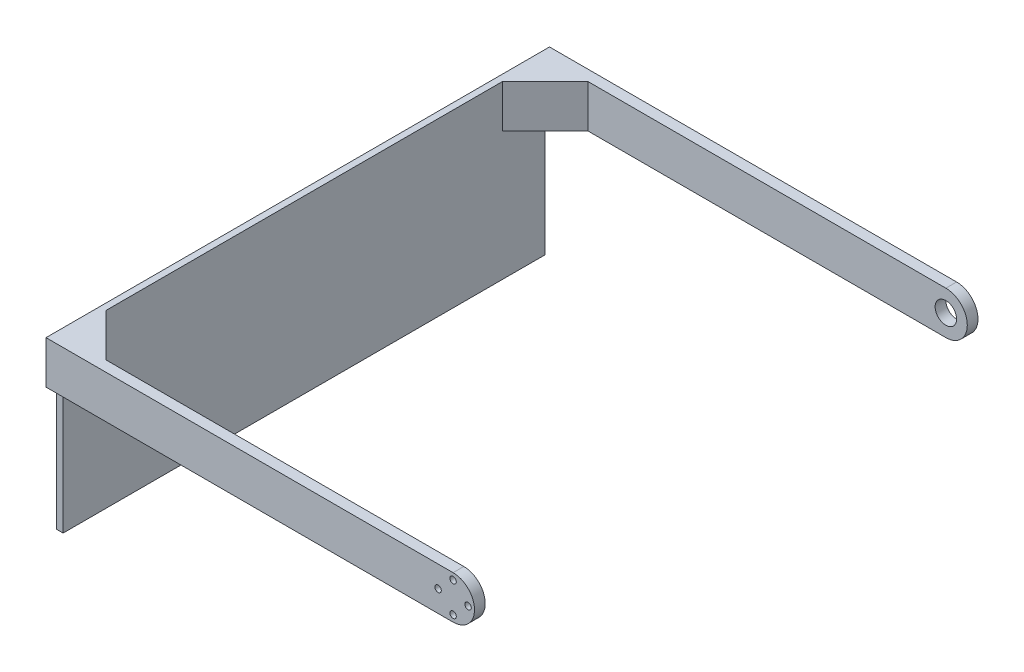
from build123d import *

# Parameters (mm, degrees)
SKETCH_1_R      = 1.5
EXTRUDE_1_DEPTH = 5
EXTRUDE_2_DEPTH = 225
RIB_1_REACH     = 307.164
SKETCH_3_WALL_W = 640.612052034
SKETCH_3_WALL_H = 20
SKETCH_4_R      = 5
EXTRUDE_3_DEPTH = 5


with BuildPart() as part:
    # 草图1 → 凸台-拉伸1 (new body)
    with BuildSketch(Plane.XY):
        with BuildLine():
            Line((0, 10), (-190, 10))
            Line((-190, 10), (-190, -10))
            Line((-190, -10), (0, -10))
            ThreePointArc((0, -10), (10, 0), (0, 10))
        make_face()
        with Locations((7, 0)):
            Circle(SKETCH_1_R, mode=Mode.SUBTRACT)
        with Locations((0, -7)):
            Circle(SKETCH_1_R, mode=Mode.SUBTRACT)
        with Locations((-7, 0)):
            Circle(SKETCH_1_R, mode=Mode.SUBTRACT)
        with Locations((0, 7)):
            Circle(SKETCH_1_R, mode=Mode.SUBTRACT)
    extrude(amount=EXTRUDE_1_DEPTH)

    # 草图2 → 凸台-拉伸2 (add)
    with BuildSketch(Plane(origin=(0, 0, 0), x_dir=(-1, 0, 0), z_dir=(0, 0, -1))):
        Polygon((190, 10), (190, -10), (190, -70), (187, -70), (187, -10), (187, 10), align=None)
    extrude(amount=EXTRUDE_2_DEPTH)

    # 草图3 wall → 筋1 (add, up to next)
    with BuildSketch(Plane(origin=(-177, 10, -10), x_dir=(0.707106781187, 0, 0.707106781187), z_dir=(0.707106781187, 0, -0.707106781187)), mode=Mode.PRIVATE) as rib_1_sk1:
        with Locations((0, 10)):
            Rectangle(SKETCH_3_WALL_W, SKETCH_3_WALL_H)
    rib_1_tool1 = extrude(rib_1_sk1.sketch, amount=-RIB_1_REACH, mode=Mode.PRIVATE) - part.part
    rib_1 = rib_1_tool1.solids().sort_by_distance((-177, 10, -10))[0]
    add(rib_1)

    # 草图4 → 凸台-拉伸3 (add)
    with BuildSketch(Plane(origin=(0, 0, -225), x_dir=(-1, 0, 0), z_dir=(0, 0, -1))):
        with BuildLine():
            Line((190, -10), (190, 10))
            Line((190, 10), (0, 10))
            ThreePointArc((0, 10), (-10, 0), (0, -10))
            Line((0, -10), (190, -10))
        make_face()
        Circle(SKETCH_4_R, mode=Mode.SUBTRACT)
    extrude(amount=EXTRUDE_3_DEPTH)

    # 镜向1: 筋1 across plane
    add(rib_1.mirror(Plane.XY.offset(-112.5)))


solid = part.part
